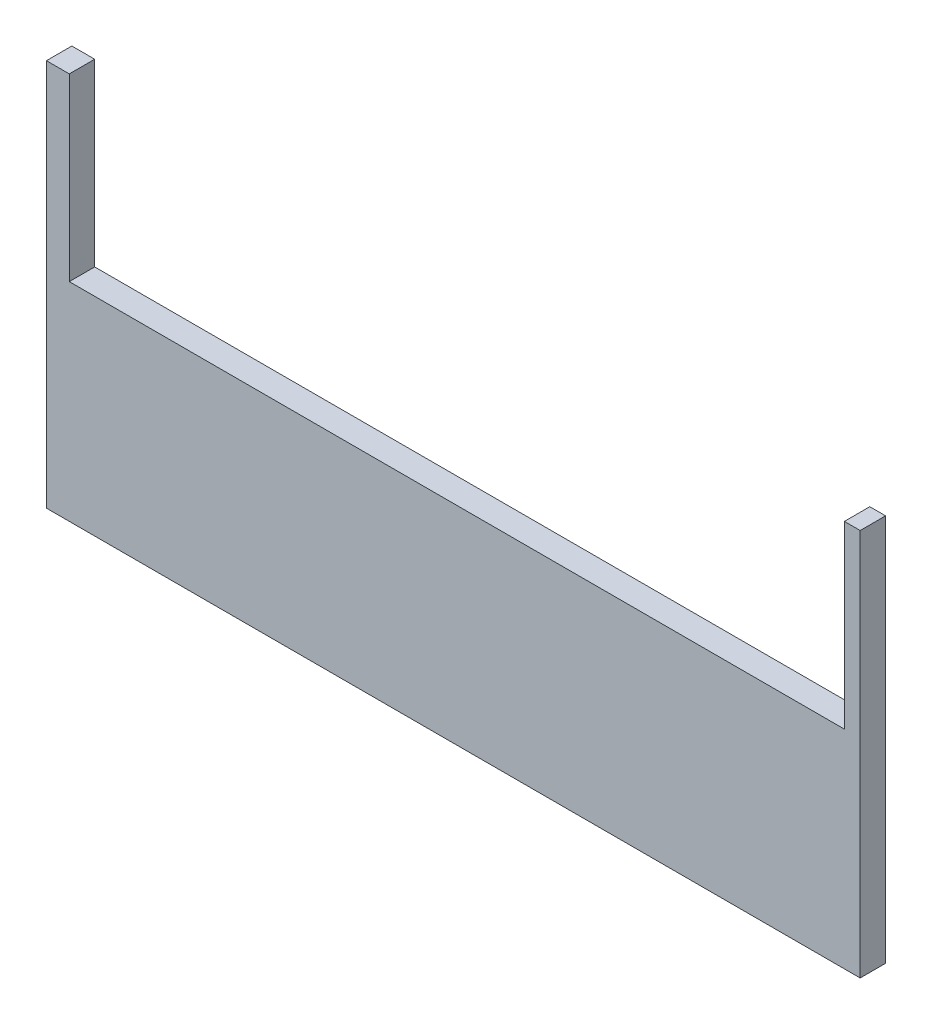
from build123d import *

# Parameters (mm, degrees)
SKETCH2_W               = 320
SKETCH2_H               = 152.4
BOSS_EXTRUDE2_DEPTH     = 10
SKETCH7_W               = 304.8
SKETCH7_H               = 75.37972508
CUT_EXTRUDE1_DEPTH      = 1
CUT_EXTRUDE1_DEPTH_BACK = 11


with BuildPart() as part:
    # Sketch2 → Boss-Extrude2 (new body)
    with BuildSketch(Plane.XY):
        with Locations((160, 76.2)):
            Rectangle(SKETCH2_W, SKETCH2_H)
    extrude(amount=BOSS_EXTRUDE2_DEPTH)

    # Sketch7 → Cut-Extrude1 (cut, two sides)
    with BuildSketch(Plane.XY.offset(10)) as cut_extrude1_sk:
        with Locations((161.389929353, 119.344096734)):
            Rectangle(SKETCH7_W, SKETCH7_H)
    extrude(amount=CUT_EXTRUDE1_DEPTH, mode=Mode.SUBTRACT)
    extrude(cut_extrude1_sk.sketch, amount=-CUT_EXTRUDE1_DEPTH_BACK, mode=Mode.SUBTRACT)


solid = part.part
